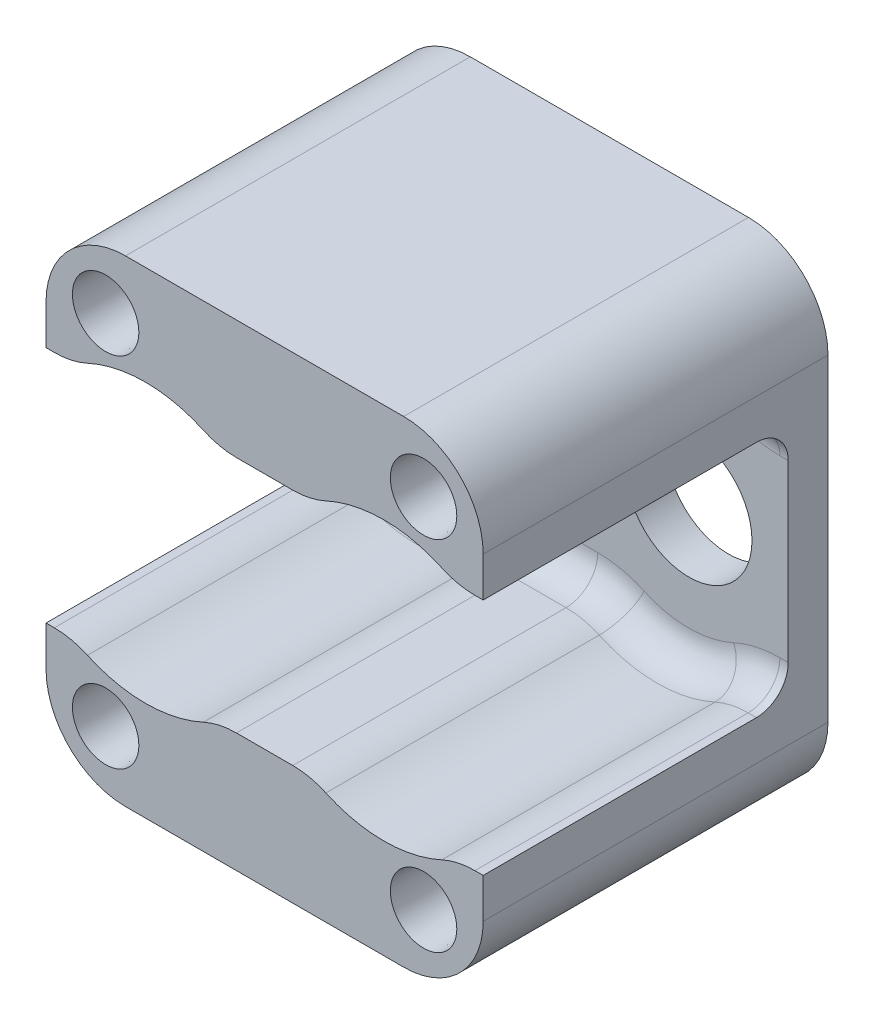
from build123d import *

# Parameters (mm, degrees)
SKETCH1_W               = 34.925
SKETCH1_H               = 38.1
BOSS_EXTRUDE1_DEPTH     = 3.175
SKETCH2_W               = 34.925
SKETCH2_H               = 9.525
BOSS_EXTRUDE2_DEPTH     = 24.3713
CUT_EXTRUDE1_START      = -16.4338
SKETCH3_R               = 11.1125
CUT_EXTRUDE1_DEPTH      = 25.3713
FILLET1_R               = 6.35
FILLET2_R               = 2.54
SKETCH4_R               = 4.9022
CUT_EXTRUDE2_DEPTH      = 4.175
F_3_8_CLEARANCE_HOLE1_D = 10.0838
F_6_CLEARANCE_HOLE1_D   = 4.3053
HOLE1_AT_2_COUNT        = 2
HOLE1_AT_2_PITCH        = 25.4
HOLE1_AT_3_COUNT        = 2
HOLE1_AT_3_PITCH        = 28.575
HOLE1_AT_4_COUNT        = 2
HOLE1_AT_4_PITCH        = 38.232062788
CUT_EXTRUDE3_REACH      = 29.546
SKETCH11_R              = 1.5875


with BuildPart() as part:
    # Sketch1 → Boss-Extrude1 (new body)
    with BuildSketch(Plane.XY):
        with Locations((-9.525, 0)):
            Rectangle(SKETCH1_W, SKETCH1_H)
    extrude(amount=BOSS_EXTRUDE1_DEPTH)

    # Sketch2 → Boss-Extrude2 (add)
    with BuildSketch(Plane.XY.offset(3.175)):
        with Locations((-9.525, 14.2875)):
            Rectangle(SKETCH2_W, SKETCH2_H)
    boss_extrude2 = extrude(amount=BOSS_EXTRUDE2_DEPTH)

    # Sketch3 → Cut-Extrude1 (cut)
    with BuildSketch(Plane.XY.offset(19.6088).offset(CUT_EXTRUDE1_START)):
        Circle(SKETCH3_R)
        with Locations((-19.05, 0)):
            Circle(SKETCH3_R)
    cut_extrude1 = extrude(amount=CUT_EXTRUDE1_DEPTH, mode=Mode.SUBTRACT)

    # Mirror1: Boss-Extrude2, Cut-Extrude1 across plane
    add(boss_extrude2.mirror(Plane.ZX))
    add(cut_extrude1.mirror(Plane.ZX), mode=Mode.SUBTRACT)

    # Fillet1
    fillet1_edges = [part.edges().sort_by_distance(p)[0] for p in [
        (7.9375, 19.05, 13.77315),
        (-26.9875, 19.05, 13.77315),
        (5.72381265, 9.525, 15.36065),
        (-5.72381265, 9.525, 15.36065),
        (-13.32618735, 9.525, 15.36065),
        (-24.77381265, 9.525, 15.36065),
        (7.9375, -19.05, 13.77315),
        (-26.9875, -19.05, 13.77315),
        (5.72381265, -9.525, 15.36065),
        (-5.72381265, -9.525, 15.36065),
        (-13.32618735, -9.525, 15.36065),
        (-24.77381265, -9.525, 15.36065),
    ]]
    fillet(fillet1_edges, radius=FILLET1_R)

    # Fillet2
    fillet2_edges = [part.edges().sort_by_distance(p)[0] for p in [
        (7.606169458, 9.525, 3.175),
        (5.921014367, 9.670996527, 3.175),
        (0, 11.1125, 3.175),
        (-5.921014367, 9.670996527, 3.175),
        (-9.525, 9.525, 3.175),
        (-13.128985633, 9.670996527, 3.175),
        (-19.05, 11.1125, 3.175),
        (-24.971014367, 9.670996527, 3.175),
        (-26.656169458, 9.525, 3.175),
        (7.606169458, -9.525, 3.175),
        (5.921014367, -9.670996527, 3.175),
        (0, -11.1125, 3.175),
        (-5.921014367, -9.670996527, 3.175),
        (-9.525, -9.525, 3.175),
        (-13.128985633, -9.670996527, 3.175),
        (-19.05, -11.1125, 3.175),
        (-24.971014367, -9.670996527, 3.175),
        (-26.656169458, -9.525, 3.175),
    ]]
    fillet(fillet2_edges, radius=FILLET2_R)

    # Sketch4 → Cut-Extrude2 (cut, through all)
    with BuildSketch(Plane.XY.offset(3.175)):
        with Locations((-19.05, 0)):
            Circle(SKETCH4_R)
    extrude(amount=-CUT_EXTRUDE2_DEPTH, mode=Mode.SUBTRACT)

    # 3/8 Clearance Hole1 (through all)
    with Locations(Plane.XY.offset(3.175)):
        with Locations((0, 0)):
            Hole(F_3_8_CLEARANCE_HOLE1_D / 2)

    # #6 Clearance Hole1 (through all)
    with Locations(Plane(origin=(0, 0, 0), x_dir=(-1, 0, 0), z_dir=(0, 0, -1))):
        with Locations((-3.175, 14.2875), (22.225, 14.2875), (22.225, -14.2875), (-3.175, -14.2875)):
            Hole(F_6_CLEARANCE_HOLE1_D / 2)

    # Sketch9 → Hole1 (revolve, cut)
    with BuildSketch(Plane(origin=(-22.225, 14.2875, 27.5463), x_dir=(0, -1, 0), z_dir=(1, 0, 0))):
        Polygon((0, 0), (0, 3.81), (2.5273, 3.81), (2.6543, 0), align=None)
    hole1 = revolve(axis=Axis((-22.225, 14.2875, -82.4537), (0, 0, 1)), mode=Mode.SUBTRACT)

    # Hole1 at 2: Hole1 ×2
    with Locations(*[(i * HOLE1_AT_2_PITCH, 0, 0) for i in range(1, HOLE1_AT_2_COUNT)]):
        add(hole1, mode=Mode.SUBTRACT)

    # Hole1 at 3: Hole1 ×2
    with Locations(*[(0, -i * HOLE1_AT_3_PITCH, 0) for i in range(1, HOLE1_AT_3_COUNT)]):
        add(hole1, mode=Mode.SUBTRACT)

    # Hole1 at 4: Hole1 ×2
    with Locations(*[Vector(0.664363839, -0.747409319, 0) * (i * HOLE1_AT_4_PITCH) for i in range(1, HOLE1_AT_4_COUNT)]):
        add(hole1, mode=Mode.SUBTRACT)

    # Sketch11 → Cut-Extrude3 (cut, up to next)
    with BuildSketch(Plane(origin=(0, 0, 0), x_dir=(-1, 0, 0), z_dir=(0, 0, -1)), mode=Mode.PRIVATE) as cut_extrude3_sk1:
        with Locations((23.8252, -8.270889016)):
            Circle(SKETCH11_R)
    cut_extrude3_tool1 = extrude(cut_extrude3_sk1.sketch, amount=-CUT_EXTRUDE3_REACH, mode=Mode.PRIVATE) & part.part
    add(cut_extrude3_tool1.solids().sort_by_distance((-23.8252, -8.270889, 0))[0], mode=Mode.SUBTRACT)

    # Sketch12 → Hole2 (revolve, cut)
    with BuildSketch(Plane(origin=(-22.225, 14.2875, 0), x_dir=(0, 1, 0), z_dir=(1, 0, 0))):
        Polygon((0, 0), (0, 3.81), (2.5273, 3.81), (2.6543, 0), align=None)
    revolve(axis=Axis((-22.225, 14.2875, 110), (0, 0, -1)), mode=Mode.SUBTRACT)


solid = part.part
